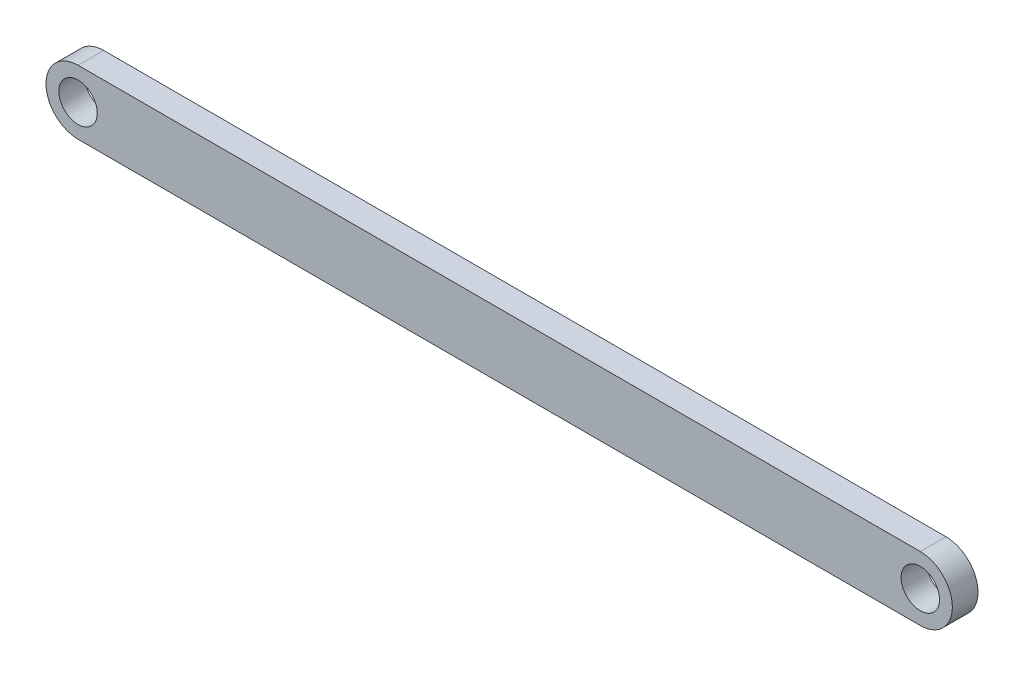
from build123d import *

# Parameters (mm, degrees)
SKETCH1_R           = 1.5
BOSS_EXTRUDE1_DEPTH = 2


with BuildPart() as part:
    # Sketch1 → Boss-Extrude1 (new body)
    with BuildSketch(Plane.XY):
        with BuildLine():
            Line((0.094462013, 2.491682866), (65.794462013, 2.491682866))
            ThreePointArc((65.794462013, 2.491682866), (68.294462013, -0.008317134), (65.794462013, -2.508317134))
            Line((65.794462013, -2.508317134), (0.094462013, -2.508317134))
            ThreePointArc((0.094462013, -2.508317134), (-2.405537987, -0.008317134), (0.094462013, 2.491682866))
        make_face()
        with Locations((0.094462013, -0.008317134)):
            Circle(SKETCH1_R, mode=Mode.SUBTRACT)
        with Locations((65.794462013, -0.008317134)):
            Circle(SKETCH1_R, mode=Mode.SUBTRACT)
    extrude(amount=BOSS_EXTRUDE1_DEPTH)


solid = part.part
